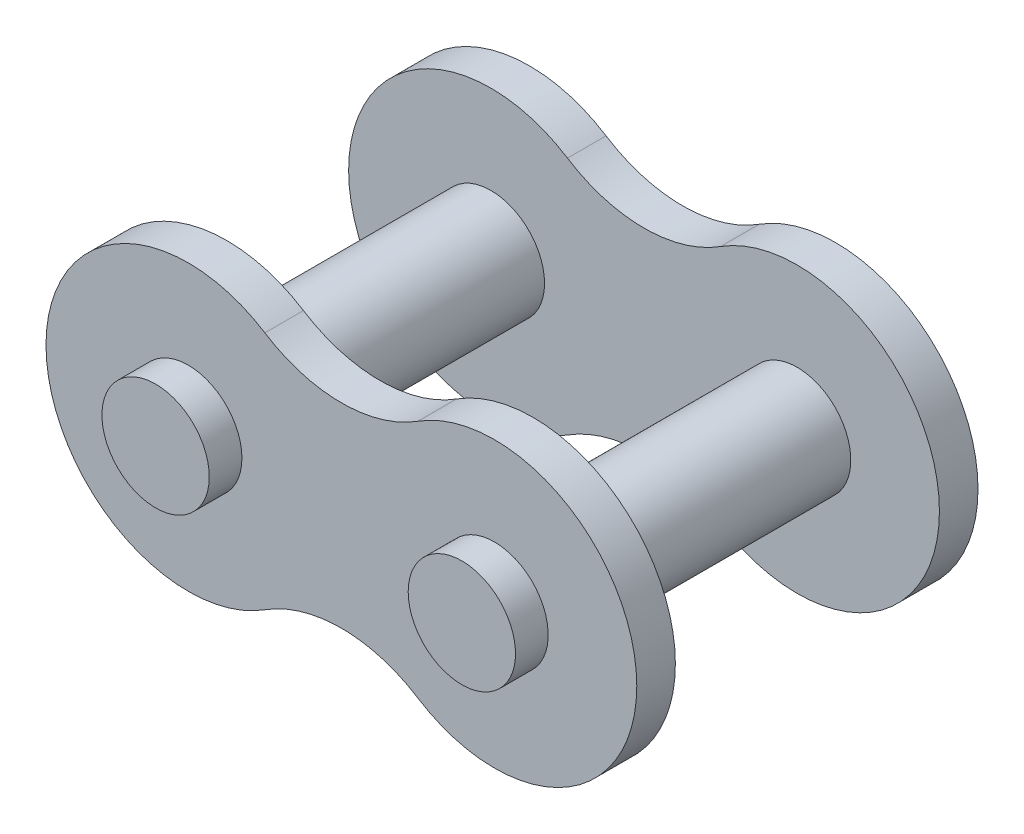
from build123d import *

# Parameters (mm, degrees)
EXTRUDE_START   = -5.475
EXTRUDE_1_DEPTH = 1.6
SKETCH_1_3_R    = 2.225
EXTRUDE_2_DEPTH = 8.43


with BuildPart() as part:
    # Эскиз1 → Бобышка-Вытянуть1 (new body)
    with BuildSketch(Plane.XY.offset(EXTRUDE_START)):
        with BuildLine():
            Line((0, 4.045727726), (0, -4.045727726))
            ThreePointArc((0, -4.045727726), (-1.653799143, -4.282252786), (-3.175, -4.972863863))
            ThreePointArc((-3.175, -4.972863863), (-12.25, 0), (-3.175, 4.972863863))
            ThreePointArc((-3.175, 4.972863863), (-1.653799143, 4.282252786), (0, 4.045727726))
        make_face()
    extrude(amount=-EXTRUDE_1_DEPTH)

    # Эскиз1<3> → Бобышка-Вытянуть2 (add)
    with BuildSketch(Plane.XY):
        with Locations((-6.35, 0)):
            Circle(SKETCH_1_3_R)
    extrude(amount=-EXTRUDE_2_DEPTH)

    # Зеркальное отражение1: part across plane


with BuildPart() as part_1:
    add(part.part)
    add(part.part.mirror(Plane(origin=(0, 0, 0), x_dir=(0, 0, 1), z_dir=(1, 0, 0))))

    # Зеркальное отражение2: part across plane


with BuildPart() as part_2:
    add(part_1.part)
    add(part_1.part.mirror(Plane.XY))


solid = part_2.part
